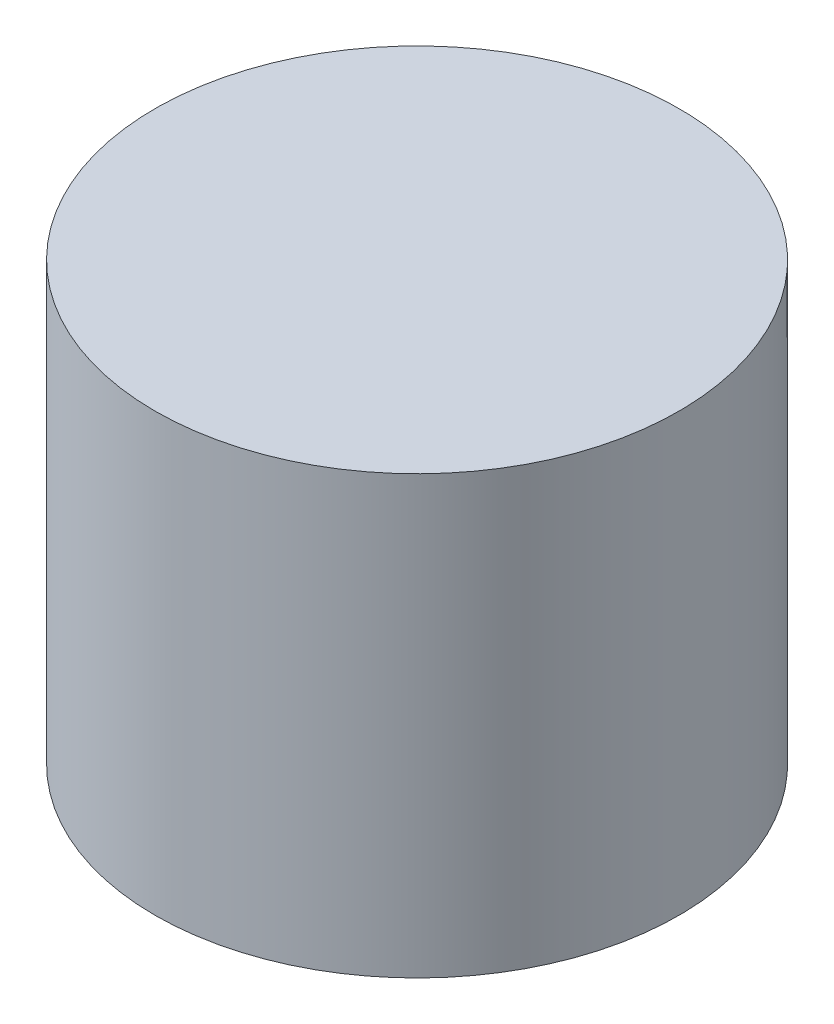
from build123d import *

# Parameters (mm, degrees)
SKETCH1_R           = 1.5
BOSS_EXTRUDE1_DEPTH = 2.5


with BuildPart() as part:
    # Sketch1 → Boss-Extrude1 (new body)
    with BuildSketch(Plane(origin=(0, 0, 0), x_dir=(1, 0, 0), z_dir=(0, 1, 0))):
        Circle(SKETCH1_R)
    extrude(amount=BOSS_EXTRUDE1_DEPTH)


solid = part.part
